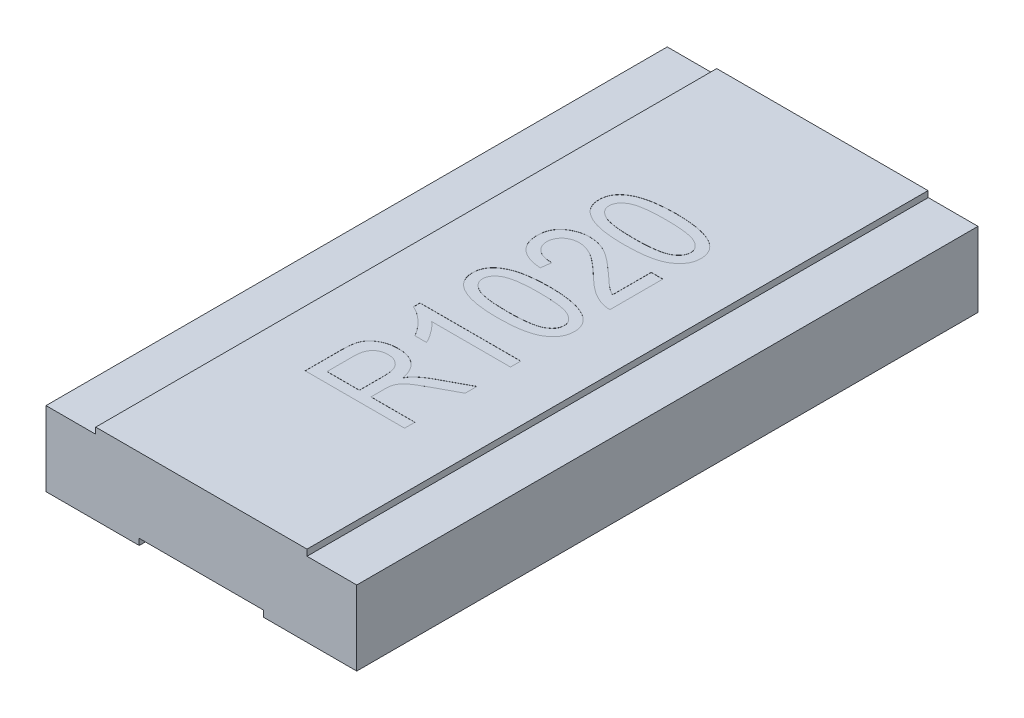
from build123d import *

# Parameters (mm, degrees)
SKETCH1_W           = 2.4
SKETCH1_H           = 0.5
BOSS_EXTRUDE1_DEPTH = 2.5
BOSS_EXTRUDE4_DEPTH = 2.499
SKETCH6_W           = 1.7
SKETCH6_H           = 0.1
BOSS_EXTRUDE6_DEPTH = 2.498
CUT_EXTRUDE1_DEPTH  = 0.001


with BuildPart() as part:
    # Sketch1 → Boss-Extrude1 (new body, symmetric)
    with BuildSketch(Plane.XY):
        with Locations((0, 0.25)):
            Rectangle(SKETCH1_W, SKETCH1_H)
    extrude(amount=BOSS_EXTRUDE1_DEPTH, both=True)

    # Sketch4 → Boss-Extrude4 (add, symmetric)
    with BuildSketch(Plane.XY.offset(0.001)):
        Polygon((-0.85, 0.5), (-1.2, 0.5), (-1.2, 0), (-0.5, 0), (-0.5, -0.05), (-1.25, -0.05), (-1.25, 0.55), (-0.85, 0.55), align=None)
        Polygon((0.5, 0), (0.5, -0.05), (1.25, -0.05), (1.25, 0.55), (0.85, 0.55), (0.85, 0.5), (1.2, 0.5), (1.2, 0), align=None)
    extrude(amount=BOSS_EXTRUDE4_DEPTH, both=True)

    # Sketch6 → Boss-Extrude6 (add, symmetric)
    with BuildSketch(Plane.XY.offset(0.002)):
        with Locations((0, 0.55)):
            Rectangle(SKETCH6_W, SKETCH6_H)
    extrude(amount=BOSS_EXTRUDE6_DEPTH, both=True)

    # Sketch7 → Cut-Extrude1 (cut)
    with BuildSketch(Plane(origin=(0, 0.6, 0), x_dir=(1, 0, 0), z_dir=(0, 1, 0))):
        with BuildLine():
            Line((0.4, -1.265101547), (-0.4, -1.265101547))
            Line((-0.4, -1.265101547), (-0.4, -0.971270379))
            add(Edge.make_bspline(
                [(-0.4, -0.971270379), (-0.39995785, -0.963855116), (-0.399876264, -0.949502111), (-0.398680595, -0.92871139), (-0.396945836, -0.909373199), (-0.394525945, -0.891550439), (-0.391555504, -0.875247766), (-0.387561775, -0.860533054), (-0.383180064, -0.847201773), (-0.375944491, -0.831509786), (-0.364511837, -0.813744854), (-0.347436487, -0.794426273), (-0.326220815, -0.777569521), (-0.30187047, -0.762556091), (-0.274523417, -0.750230301), (-0.244701857, -0.741498445), (-0.212795149, -0.736227432), (-0.190821454, -0.735569197), (-0.179545455, -0.735231418)],
                knots=[0, 0, 0, 0, 2.2243e-05, 4.3053e-05, 6.2453e-05, 8.0476e-05, 9.7e-05, 0.000112121, 0.000126187, 0.000139045, 0.000163859, 0.000189272, 0.000216045, 0.000244834, 0.000274916, 0.000305734, 0.000337814, 0.000371627, 0.000371627, 0.000371627, 0.000371627], degree=3))
            add(Edge.make_bspline(
                [(-0.179545455, -0.735231418), (-0.172073315, -0.73540863), (-0.157477891, -0.735754781), (-0.136082698, -0.737836039), (-0.115748432, -0.741507088), (-0.096577728, -0.746961367), (-0.078391935, -0.753512258), (-0.061438311, -0.761920334), (-0.045471195, -0.771634303), (-0.030623881, -0.782898063), (-0.016999042, -0.795586057), (-0.004519285, -0.809571398), (0.006298816, -0.825172308), (0.016103374, -0.84190487), (0.02456307, -0.860059036), (0.031704326, -0.879545814), (0.037352601, -0.900433785), (0.040135474, -0.91486519), (0.041558442, -0.922244405)],
                knots=[0, 0, 0, 0, 2.2417e-05, 4.3788e-05, 6.4421e-05, 8.4312e-05, 0.000103521, 0.000122325, 0.000140979, 0.000159518, 0.000178127, 0.000196758, 0.00021563, 0.000234981, 0.00025488, 0.000275628, 0.00029717, 0.000319711, 0.000319711, 0.000319711, 0.000319711], degree=3))
            add(Edge.make_bspline(
                [(0.041558442, -0.922244405), (0.044555926, -0.916779777), (0.050276332, -0.90635107), (0.059782903, -0.892318905), (0.068890204, -0.880021833), (0.075678481, -0.873203531), (0.078896104, -0.869971677)],
                knots=[0, 0, 0, 0, 1.8686e-05, 3.566e-05, 5.0824e-05, 6.4488e-05, 6.4488e-05, 6.4488e-05, 6.4488e-05], degree=3))
            add(Edge.make_bspline(
                [(0.078896104, -0.869971677), (0.086721081, -0.863488896), (0.102459028, -0.850450434), (0.127566949, -0.832576778), (0.153686209, -0.81545617), (0.172059762, -0.805402143), (0.181331169, -0.80032882)],
                knots=[0, 0, 0, 0, 3.0475e-05, 6.1292e-05, 9.2407e-05, 0.000124101, 0.000124101, 0.000124101, 0.000124101], degree=3))
            Line((0.181331169, -0.80032882), (0.4, -0.683283366))
            Line((0.4, -0.683283366), (0.4, -0.777763885))
            Line((0.4, -0.777763885), (0.228896104, -0.870134015))
            add(Edge.make_bspline(
                [(0.228896104, -0.870134015), (0.220873279, -0.874437048), (0.205527529, -0.882667722), (0.183738651, -0.894882687), (0.164088927, -0.906238078), (0.146556532, -0.916711609), (0.131335827, -0.926468311), (0.118191897, -0.935209203), (0.107318298, -0.943305263), (0.095943991, -0.952720948), (0.084495486, -0.964071732), (0.072798294, -0.977253692), (0.063759525, -0.990514275), (0.056864975, -1.004000115), (0.052325538, -1.018849089), (0.048926934, -1.035579824), (0.047078549, -1.054942071), (0.04686627, -1.068669394), (0.046753247, -1.075978171)],
                knots=[0, 0, 0, 0, 2.7311e-05, 5.224e-05, 7.4933e-05, 9.5396e-05, 0.000113499, 0.000129168, 0.00014274, 0.000154151, 0.000173437, 0.000191045, 0.000206939, 0.000221459, 0.000236296, 0.000253361, 0.000272615, 0.000294541, 0.000294541, 0.000294541, 0.000294541], degree=3))
            Line((0.046753247, -1.075978171), (0.046753247, -1.181984664))
            Line((0.046753247, -1.181984664), (0.4, -1.181984664))
            Line((0.4, -1.181984664), (0.4, -1.265101547))
        make_face()
        with BuildLine():
            Line((-0.046753247, -1.181984664), (-0.046753247, -0.987017132))
            add(Edge.make_bspline(
                [(-0.046753247, -0.987017132), (-0.046948354, -0.977001093), (-0.047314005, -0.95823006), (-0.049742591, -0.931969507), (-0.054137093, -0.909554996), (-0.060538394, -0.890569429), (-0.069017501, -0.874376486), (-0.079527286, -0.860291509), (-0.092074494, -0.847857466), (-0.106691715, -0.837504803), (-0.122754899, -0.828656947), (-0.140496417, -0.822848764), (-0.159345231, -0.818852845), (-0.172380378, -0.81851922), (-0.179058442, -0.818348301)],
                knots=[0, 0, 0, 0, 3.0048e-05, 5.6313e-05, 7.9013e-05, 9.8419e-05, 0.00011621, 0.000133613, 0.000150946, 0.000168969, 0.000187198, 0.000205731, 0.00022477, 0.00024477, 0.00024477, 0.00024477, 0.00024477], degree=3))
            add(Edge.make_bspline(
                [(-0.179058442, -0.818348301), (-0.183878219, -0.818496201), (-0.193274501, -0.818784536), (-0.207043887, -0.82035962), (-0.219990172, -0.82326522), (-0.232159497, -0.827388158), (-0.243526929, -0.832520018), (-0.254097057, -0.838962505), (-0.263769813, -0.846618565), (-0.272785251, -0.855231718), (-0.280850043, -0.865032989), (-0.28757401, -0.876161152), (-0.293475167, -0.888266536), (-0.298386538, -0.901513593), (-0.302052756, -0.915942094), (-0.304585918, -0.931480719), (-0.306284106, -0.948072585), (-0.30642228, -0.959523445), (-0.306493506, -0.965426223)],
                knots=[0, 0, 0, 0, 1.4463e-05, 2.8195e-05, 4.1507e-05, 5.4187e-05, 6.6682e-05, 7.8848e-05, 9.1221e-05, 0.000103621, 0.000116196, 0.000129171, 0.00014253, 0.000156553, 0.000171475, 0.000187115, 0.000203752, 0.000221454, 0.000221454, 0.000221454, 0.000221454], degree=3))
            Line((-0.306493506, -0.965426223), (-0.306493506, -1.181984664))
            Line((-0.306493506, -1.181984664), (-0.046753247, -1.181984664))
        make_face(mode=Mode.SUBTRACT)
        with BuildLine():
            Line((0.4, -0.330036612), (0.4, -0.413153496))
            Line((0.4, -0.413153496), (-0.233766234, -0.413153496))
            add(Edge.make_bspline(
                [(-0.233766234, -0.413153496), (-0.22789281, -0.418259983), (-0.215720145, -0.428843174), (-0.198387445, -0.447148824), (-0.180717222, -0.467729046), (-0.163347096, -0.490308414), (-0.146803147, -0.513467991), (-0.13198719, -0.536164213), (-0.119317397, -0.557883571), (-0.112407645, -0.572413015), (-0.109090909, -0.579387262)],
                knots=[0, 0, 0, 0, 2.3337e-05, 4.8365e-05, 7.5534e-05, 0.000104694, 0.000133793, 0.0001609, 0.000185989, 0.000209148, 0.000209148, 0.000209148, 0.000209148], degree=3))
            Line((-0.109090909, -0.579387262), (-0.202597403, -0.579387262))
            add(Edge.make_bspline(
                [(-0.202597403, -0.579387262), (-0.209347315, -0.56817847), (-0.222789341, -0.545856864), (-0.246047405, -0.514513351), (-0.27134637, -0.485063397), (-0.298564664, -0.45813021), (-0.326499348, -0.433908583), (-0.354510545, -0.413262457), (-0.382167744, -0.396279995), (-0.40119783, -0.387954189), (-0.41038961, -0.383932716)],
                knots=[0, 0, 0, 0, 3.9234e-05, 7.8131e-05, 0.000116922, 0.000155606, 0.0001929, 0.00022774, 0.000259924, 0.000289992, 0.000289992, 0.000289992, 0.000289992], degree=3))
            Line((-0.41038961, -0.383932716), (-0.41038961, -0.330036612))
            Line((-0.41038961, -0.330036612), (0.4, -0.330036612))
        make_face()
        with BuildLine():
            add(Edge.make_bspline(
                [(0.000324675, -0.122244405), (-0.016021042, -0.122112435), (-0.047760494, -0.121856181), (-0.09379487, -0.119207284), (-0.136801588, -0.11503034), (-0.17672127, -0.109346522), (-0.213565673, -0.101666694), (-0.247423741, -0.092569134), (-0.278200626, -0.081526289), (-0.30592122, -0.068951131), (-0.330477704, -0.054681469), (-0.351792814, -0.038669027), (-0.370041697, -0.02114344), (-0.384847394, -0.001745618), (-0.396328317, 0.019227557), (-0.404536915, 0.041819927), (-0.409503157, 0.066013289), (-0.410090123, 0.082710307), (-0.41038961, 0.091229621)],
                knots=[0, 0, 0, 0, 4.9033e-05, 9.521e-05, 0.000138274, 0.000178635, 0.000216108, 0.000251119, 0.000283726, 0.00031409, 0.000342322, 0.00036875, 0.000393892, 0.000417983, 0.000441667, 0.000465342, 0.000489857, 0.000515395, 0.000515395, 0.000515395, 0.000515395], degree=3))
            add(Edge.make_bspline(
                [(-0.41038961, 0.091229621), (-0.410169658, 0.098826563), (-0.409737438, 0.113755033), (-0.405457538, 0.135431419), (-0.399077317, 0.155985643), (-0.389661722, 0.17511877), (-0.377673073, 0.193047285), (-0.36292492, 0.209558156), (-0.345731248, 0.2250786), (-0.332693004, 0.233915813), (-0.325974026, 0.238469881)],
                knots=[0, 0, 0, 0, 2.2764e-05, 4.4733e-05, 6.6039e-05, 8.7167e-05, 0.000108463, 0.000130546, 0.000153424, 0.000177749, 0.000177749, 0.000177749, 0.000177749], degree=3))
            add(Edge.make_bspline(
                [(-0.325974026, 0.238469881), (-0.316932513, 0.243757062), (-0.298129732, 0.254752314), (-0.266625089, 0.26787697), (-0.231391283, 0.278974552), (-0.192392981, 0.288232291), (-0.149548038, 0.294953917), (-0.103030259, 0.300194582), (-0.052638354, 0.303249271), (-0.017753077, 0.303565665), (0.000324675, 0.303729621)],
                knots=[0, 0, 0, 0, 3.1393e-05, 6.5286e-05, 0.000102096, 0.000142141, 0.000185403, 0.000232121, 0.00028254, 0.00033677, 0.00033677, 0.00033677, 0.00033677], degree=3))
            add(Edge.make_bspline(
                [(0.000324675, 0.303729621), (0.016562275, 0.303598346), (0.048085644, 0.30334349), (0.093848365, 0.300683555), (0.136641334, 0.296522752), (0.176444849, 0.290804382), (0.21320116, 0.283198918), (0.246943754, 0.273969999), (0.27775117, 0.263224052), (0.305463525, 0.250547751), (0.330139101, 0.236325562), (0.35156697, 0.220422432), (0.369744183, 0.202836017), (0.384714293, 0.183615626), (0.396154173, 0.162500504), (0.4045563, 0.139909505), (0.409505394, 0.115577436), (0.410090267, 0.098828081), (0.41038961, 0.090255595)],
                knots=[0, 0, 0, 0, 4.8708e-05, 9.4561e-05, 0.000137464, 0.000177664, 0.000215137, 0.000249992, 0.000282544, 0.000312908, 0.00034128, 0.000367838, 0.00039275, 0.000416941, 0.000440624, 0.000464508, 0.000489022, 0.000514723, 0.000514723, 0.000514723, 0.000514723], degree=3))
            add(Edge.make_bspline(
                [(0.41038961, 0.090255595), (0.410102249, 0.082607501), (0.409537263, 0.067570486), (0.40525013, 0.045503476), (0.397835391, 0.02463294), (0.387715352, 0.004750146), (0.37448733, -0.013836791), (0.358603182, -0.031566733), (0.339632377, -0.048016827), (0.317846299, -0.063685929), (0.292434451, -0.077758524), (0.262894461, -0.089636104), (0.229327034, -0.099840396), (0.191493763, -0.107875867), (0.149631232, -0.114611097), (0.103536364, -0.118909919), (0.05333605, -0.12171659), (0.018456685, -0.122063871), (0.000324675, -0.122244405)],
                knots=[0, 0, 0, 0, 2.2936e-05, 4.5095e-05, 6.7121e-05, 8.9192e-05, 0.000111801, 0.000135367, 0.000160443, 0.000186976, 0.000215752, 0.000247346, 0.000282316, 0.000320878, 0.000363286, 0.000409452, 0.00045969, 0.000514082, 0.000514082, 0.000514082, 0.000514082], degree=3))
        make_face()
        with BuildLine():
            add(Edge.make_bspline(
                [(0, -0.039127522), (0.015585433, -0.038980974), (0.045412307, -0.038700515), (0.088138333, -0.037197996), (0.126801799, -0.034296169), (0.161480386, -0.030322961), (0.192171875, -0.025216691), (0.218937291, -0.019062695), (0.241618648, -0.011511026), (0.260612284, -0.00280719), (0.276390845, 0.006992362), (0.289995294, 0.017192196), (0.301500674, 0.028101141), (0.310858817, 0.039751232), (0.318307973, 0.05198922), (0.323544637, 0.064977356), (0.32676959, 0.078625897), (0.327103684, 0.087965203), (0.327272727, 0.09269066)],
                knots=[0, 0, 0, 0, 4.6758e-05, 8.9483e-05, 0.00012823, 0.000163045, 0.000194164, 0.00022153, 0.00024535, 0.000265758, 0.000284051, 0.000300967, 0.000316697, 0.000331477, 0.000345676, 0.000359513, 0.000373336, 0.000387492, 0.000387492, 0.000387492, 0.000387492], degree=3))
            add(Edge.make_bspline(
                [(0.327272727, 0.09269066), (0.327118523, 0.097150594), (0.326811477, 0.106031032), (0.323300853, 0.118978506), (0.318137694, 0.131449963), (0.310698881, 0.143317716), (0.300920242, 0.154317546), (0.289296481, 0.164953664), (0.27557117, 0.17499212), (0.259580996, 0.184577709), (0.240515874, 0.193369637), (0.217644644, 0.200624092), (0.190931752, 0.206860901), (0.160354738, 0.212017235), (0.125814937, 0.215717867), (0.087382896, 0.218698347), (0.044978911, 0.220179225), (0.015422904, 0.22046409), (0, 0.220612738)],
                knots=[0, 0, 0, 0, 1.3347e-05, 2.6577e-05, 3.9963e-05, 5.3747e-05, 6.8362e-05, 8.3988e-05, 0.000100937, 0.000119284, 0.00013984, 0.000163763, 0.000191128, 0.000222087, 0.000256722, 0.000295307, 0.000337708, 0.000383979, 0.000383979, 0.000383979, 0.000383979], degree=3))
            add(Edge.make_bspline(
                [(0, 0.220612738), (-0.015585365, 0.220464955), (-0.04546618, 0.22018162), (-0.088247116, 0.218691318), (-0.127016652, 0.215768381), (-0.161752921, 0.211822751), (-0.192495499, 0.20669937), (-0.219264814, 0.200552343), (-0.241934804, 0.192983582), (-0.260920639, 0.184349607), (-0.276556352, 0.174422289), (-0.290225728, 0.164365976), (-0.30144006, 0.153159855), (-0.310923572, 0.141563039), (-0.31829914, 0.129157868), (-0.323577556, 0.1159721), (-0.326752016, 0.102094957), (-0.327098428, 0.092598656), (-0.327272727, 0.08782053)],
                knots=[0, 0, 0, 0, 4.6758e-05, 8.9646e-05, 0.000128392, 0.000163369, 0.000194487, 0.000221853, 0.000245673, 0.000266082, 0.000284236, 0.000301152, 0.000316879, 0.000331659, 0.000345998, 0.000359985, 0.000374124, 0.000388443, 0.000388443, 0.000388443, 0.000388443], degree=3))
            add(Edge.make_bspline(
                [(-0.327272727, 0.08782053), (-0.327122931, 0.083359578), (-0.326826428, 0.07452969), (-0.323295988, 0.061694161), (-0.318147158, 0.049370028), (-0.310636877, 0.03771437), (-0.301094319, 0.026629206), (-0.289497135, 0.016037577), (-0.275672715, 0.006205747), (-0.259757937, -0.003509582), (-0.240540042, -0.011904231), (-0.217800732, -0.019407358), (-0.191008933, -0.025315012), (-0.160412785, -0.030540162), (-0.125813369, -0.034228301), (-0.08738338, -0.037214473), (-0.044978772, -0.038693622), (-0.015422856, -0.038978741), (0, -0.039127522)],
                knots=[0, 0, 0, 0, 1.3347e-05, 2.6419e-05, 3.9656e-05, 5.3303e-05, 6.7812e-05, 8.3438e-05, 0.000100291, 0.000118638, 0.000139275, 0.000163043, 0.000190372, 0.00022149, 0.000256126, 0.00029471, 0.000337112, 0.000383382, 0.000383382, 0.000383382, 0.000383382], degree=3))
        make_face(mode=Mode.SUBTRACT)
        with BuildLine():
            Line((0.306493506, 0.81282053), (0.4, 0.81282053))
            Line((0.4, 0.81282053), (0.4, 0.386846504))
            add(Edge.make_bspline(
                [(0.4, 0.386846504), (0.39512792, 0.386826782), (0.385257008, 0.386786823), (0.37020793, 0.388115329), (0.354794505, 0.390844858), (0.338811118, 0.394330191), (0.322467973, 0.399272002), (0.305685704, 0.405321741), (0.288505921, 0.412459716), (0.270827561, 0.420818377), (0.252478278, 0.430582857), (0.233546317, 0.442378477), (0.213679968, 0.45585768), (0.193126969, 0.471347035), (0.171691966, 0.488567877), (0.149474239, 0.507605191), (0.126351708, 0.52837947), (0.110993752, 0.543183486), (0.103084416, 0.550807543)],
                knots=[0, 0, 0, 0, 1.4611e-05, 2.9603e-05, 4.5242e-05, 6.1547e-05, 7.8651e-05, 9.6418e-05, 0.000115049, 0.000134438, 0.000155065, 0.000177367, 0.000201321, 0.000227067, 0.00025455, 0.000283797, 0.000314832, 0.000347786, 0.000347786, 0.000347786, 0.000347786], degree=3))
            add(Edge.make_bspline(
                [(0.103084416, 0.550807543), (0.09392156, 0.559666289), (0.076279193, 0.576723114), (0.050229157, 0.600728966), (0.026015973, 0.622540694), (0.003201794, 0.641722513), (-0.017902657, 0.658614971), (-0.037267205, 0.673388025), (-0.055331317, 0.685335669), (-0.076586339, 0.698235728), (-0.101890107, 0.710534101), (-0.131385651, 0.72140656), (-0.159899065, 0.72843156), (-0.178697352, 0.729287873), (-0.187824675, 0.729703647)],
                knots=[0, 0, 0, 0, 3.8234e-05, 7.3616e-05, 0.000106268, 0.000135991, 0.000163017, 0.000187368, 0.000209025, 0.000227956, 0.000261934, 0.00029321, 0.000322193, 0.000349548, 0.000349548, 0.000349548, 0.000349548], degree=3))
            add(Edge.make_bspline(
                [(-0.187824675, 0.729703647), (-0.192863695, 0.729645689), (-0.202705426, 0.729532489), (-0.217078053, 0.7276081), (-0.230749291, 0.724864744), (-0.243814956, 0.721238926), (-0.256071162, 0.716111803), (-0.267603487, 0.709898763), (-0.278563817, 0.702794318), (-0.288571569, 0.694504092), (-0.297599959, 0.685442291), (-0.305682462, 0.675869364), (-0.312288783, 0.66562395), (-0.31776098, 0.654917179), (-0.321947988, 0.64368491), (-0.325085218, 0.631955519), (-0.326867489, 0.619693092), (-0.327136309, 0.611364994), (-0.327272727, 0.607138712)],
                knots=[0, 0, 0, 0, 1.5105e-05, 2.9502e-05, 4.3415e-05, 5.6928e-05, 7.0102e-05, 8.3175e-05, 9.6188e-05, 0.00010922, 0.000122077, 0.000134527, 0.00014673, 0.000158563, 0.000170534, 0.000182622, 0.000194928, 0.000207607, 0.000207607, 0.000207607, 0.000207607], degree=3))
            add(Edge.make_bspline(
                [(-0.327272727, 0.607138712), (-0.327177514, 0.602581898), (-0.326991654, 0.593686786), (-0.324667417, 0.580725332), (-0.321584679, 0.568291423), (-0.316711045, 0.556540481), (-0.310820669, 0.545248675), (-0.303131832, 0.534880517), (-0.294550988, 0.524839719), (-0.284484341, 0.515610027), (-0.273053691, 0.507371342), (-0.260569005, 0.499976079), (-0.246719487, 0.494015435), (-0.231847415, 0.489006155), (-0.21577474, 0.485071368), (-0.198551091, 0.482444295), (-0.180183837, 0.480516798), (-0.167537953, 0.480408602), (-0.161038961, 0.480352998)],
                knots=[0, 0, 0, 0, 1.3652e-05, 2.6649e-05, 3.9407e-05, 5.2007e-05, 6.4718e-05, 7.7512e-05, 9.0631e-05, 0.000104303, 0.000118363, 0.000132841, 0.000147741, 0.000163501, 0.000179881, 0.000197308, 0.000215739, 0.000235226, 0.000235226, 0.000235226, 0.000235226], degree=3))
            Line((-0.161038961, 0.480352998), (-0.171428571, 0.397236115))
            add(Edge.make_bspline(
                [(-0.171428571, 0.397236115), (-0.181073636, 0.398092657), (-0.1997855, 0.399754387), (-0.226873639, 0.404114642), (-0.252007272, 0.410164082), (-0.275434001, 0.417349109), (-0.29687389, 0.426374779), (-0.316719481, 0.436533359), (-0.334625583, 0.448412834), (-0.350622211, 0.461765171), (-0.364649104, 0.476478484), (-0.376840285, 0.492285242), (-0.38741355, 0.509111067), (-0.39580649, 0.527192775), (-0.40235066, 0.546410757), (-0.407029461, 0.566693385), (-0.409819822, 0.588121867), (-0.410196876, 0.602747221), (-0.41038961, 0.610223128)],
                knots=[0, 0, 0, 0, 2.9043e-05, 5.6346e-05, 8.2215e-05, 0.000106552, 0.000129766, 0.000151912, 0.000173343, 0.000194087, 0.000214295, 0.0002342, 0.000253886, 0.000273785, 0.000293857, 0.000314689, 0.000336133, 0.000358557, 0.000358557, 0.000358557, 0.000358557], degree=3))
            add(Edge.make_bspline(
                [(-0.41038961, 0.610223128), (-0.410154423, 0.618295443), (-0.409696474, 0.634013581), (-0.406632452, 0.656883457), (-0.401351124, 0.678277408), (-0.393585985, 0.698040367), (-0.384049536, 0.716387192), (-0.372205632, 0.733151946), (-0.358125112, 0.74831717), (-0.342074418, 0.761800876), (-0.324753415, 0.773720346), (-0.3066396, 0.784119995), (-0.288035554, 0.793141084), (-0.268733616, 0.800191264), (-0.248993006, 0.80607893), (-0.228514436, 0.809777687), (-0.207534202, 0.812381587), (-0.193352427, 0.81267339), (-0.186201299, 0.81282053)],
                knots=[0, 0, 0, 0, 2.4215e-05, 4.7151e-05, 6.9081e-05, 9.0154e-05, 0.000110704, 0.000130972, 0.000151535, 0.000172613, 0.000193732, 0.000214532, 0.000235226, 0.00025567, 0.000276119, 0.000296941, 0.000318024, 0.000339467, 0.000339467, 0.000339467, 0.000339467], degree=3))
            add(Edge.make_bspline(
                [(-0.186201299, 0.81282053), (-0.179758445, 0.812681896), (-0.166956679, 0.812406433), (-0.147855717, 0.810614522), (-0.129011553, 0.807451465), (-0.110242993, 0.80334438), (-0.091840651, 0.797516384), (-0.07351221, 0.790918827), (-0.055464603, 0.782916329), (-0.037344912, 0.773469851), (-0.018514493, 0.762406517), (0.001381249, 0.749160805), (0.022861937, 0.733893065), (0.045675242, 0.71629258), (0.070073484, 0.696640554), (0.095863026, 0.674683478), (0.123096534, 0.650495279), (0.141585576, 0.633467256), (0.151136364, 0.62467118)],
                knots=[0, 0, 0, 0, 1.9329e-05, 3.8406e-05, 5.7488e-05, 7.6628e-05, 9.5988e-05, 0.000115349, 0.000135046, 0.000155159, 0.000176625, 0.000200533, 0.00022684, 0.000255672, 0.000286958, 0.000320819, 0.000357272, 0.000396224, 0.000396224, 0.000396224, 0.000396224], degree=3))
            add(Edge.make_bspline(
                [(0.151136364, 0.62467118), (0.157073896, 0.619081557), (0.168420996, 0.608399339), (0.184880276, 0.593374673), (0.19964141, 0.579606966), (0.213078071, 0.567564195), (0.224902458, 0.556855314), (0.235501549, 0.548052761), (0.244358981, 0.540484067), (0.258552351, 0.529442436), (0.278572735, 0.515507509), (0.297401215, 0.505813476), (0.306493506, 0.501132219)],
                knots=[0, 0, 0, 0, 2.4463e-05, 4.6752e-05, 6.6856e-05, 8.5016e-05, 0.000100884, 0.000114706, 0.000126346, 0.000135829, 0.000168653, 0.000199307, 0.000199307, 0.000199307, 0.000199307], degree=3))
            Line((0.306493506, 0.501132219), (0.306493506, 0.81282053))
        make_face()
        with BuildLine():
            add(Edge.make_bspline(
                [(0.000324675, 0.895937414), (-0.016021042, 0.896069384), (-0.047760494, 0.896325637), (-0.09379487, 0.898974535), (-0.136801588, 0.903151478), (-0.17672127, 0.908835297), (-0.213565673, 0.916515125), (-0.247423741, 0.925612684), (-0.278200626, 0.936655529), (-0.30592122, 0.949230687), (-0.330477704, 0.963500349), (-0.351792814, 0.979512791), (-0.370041697, 0.997038378), (-0.384847394, 1.016436201), (-0.396328317, 1.037409375), (-0.404536915, 1.060001745), (-0.409503157, 1.084195108), (-0.410090123, 1.100892125), (-0.41038961, 1.10941144)],
                knots=[0, 0, 0, 0, 4.9033e-05, 9.521e-05, 0.000138274, 0.000178635, 0.000216108, 0.000251119, 0.000283726, 0.00031409, 0.000342322, 0.00036875, 0.000393892, 0.000417983, 0.000441667, 0.000465342, 0.000489857, 0.000515395, 0.000515395, 0.000515395, 0.000515395], degree=3))
            add(Edge.make_bspline(
                [(-0.41038961, 1.10941144), (-0.410169658, 1.117008382), (-0.409737438, 1.131936852), (-0.405457538, 1.153613237), (-0.399077317, 1.174167461), (-0.389661722, 1.193300588), (-0.377673073, 1.211229103), (-0.36292492, 1.227739974), (-0.345731248, 1.243260418), (-0.332693004, 1.252097632), (-0.325974026, 1.256651699)],
                knots=[0, 0, 0, 0, 2.2764e-05, 4.4733e-05, 6.6039e-05, 8.7167e-05, 0.000108463, 0.000130546, 0.000153424, 0.000177749, 0.000177749, 0.000177749, 0.000177749], degree=3))
            add(Edge.make_bspline(
                [(-0.325974026, 1.256651699), (-0.316932513, 1.261938881), (-0.298129732, 1.272934132), (-0.266625089, 1.286058788), (-0.231391283, 1.29715637), (-0.192392981, 1.306414109), (-0.149548038, 1.313135735), (-0.103030259, 1.3183764), (-0.052638354, 1.32143109), (-0.017753077, 1.321747483), (0.000324675, 1.32191144)],
                knots=[0, 0, 0, 0, 3.1393e-05, 6.5286e-05, 0.000102096, 0.000142141, 0.000185403, 0.000232121, 0.00028254, 0.00033677, 0.00033677, 0.00033677, 0.00033677], degree=3))
            add(Edge.make_bspline(
                [(0.000324675, 1.32191144), (0.016562275, 1.321780164), (0.048085644, 1.321525308), (0.093848365, 1.318865374), (0.136641334, 1.31470457), (0.176444849, 1.3089862), (0.21320116, 1.301380736), (0.246943754, 1.292151817), (0.27775117, 1.28140587), (0.305463525, 1.268729569), (0.330139101, 1.25450738), (0.35156697, 1.23860425), (0.369744183, 1.221017836), (0.384714293, 1.201797444), (0.396154173, 1.180682322), (0.4045563, 1.158091324), (0.409505394, 1.133759254), (0.410090267, 1.117009899), (0.41038961, 1.108437414)],
                knots=[0, 0, 0, 0, 4.8708e-05, 9.4561e-05, 0.000137464, 0.000177664, 0.000215137, 0.000249992, 0.000282544, 0.000312908, 0.00034128, 0.000367838, 0.00039275, 0.000416941, 0.000440624, 0.000464508, 0.000489022, 0.000514723, 0.000514723, 0.000514723, 0.000514723], degree=3))
            add(Edge.make_bspline(
                [(0.41038961, 1.108437414), (0.410102249, 1.100789319), (0.409537263, 1.085752304), (0.40525013, 1.063685294), (0.397835391, 1.042814758), (0.387715352, 1.022931964), (0.37448733, 1.004345027), (0.358603182, 0.986615085), (0.339632377, 0.970164991), (0.317846299, 0.95449589), (0.292434451, 0.940423295), (0.262894461, 0.928545714), (0.229327034, 0.918341422), (0.191493763, 0.910305951), (0.149631232, 0.903570721), (0.103536364, 0.899271899), (0.05333605, 0.896465228), (0.018456685, 0.896117947), (0.000324675, 0.895937414)],
                knots=[0, 0, 0, 0, 2.2936e-05, 4.5095e-05, 6.7121e-05, 8.9192e-05, 0.000111801, 0.000135367, 0.000160443, 0.000186976, 0.000215752, 0.000247346, 0.000282316, 0.000320878, 0.000363286, 0.000409452, 0.00045969, 0.000514082, 0.000514082, 0.000514082, 0.000514082], degree=3))
        make_face()
        with BuildLine():
            add(Edge.make_bspline(
                [(0, 0.979054297), (0.015585433, 0.979200845), (0.045412307, 0.979481303), (0.088138333, 0.980983822), (0.126801799, 0.983885649), (0.161480386, 0.987858857), (0.192171875, 0.992965127), (0.218937291, 0.999119123), (0.241618648, 1.006670792), (0.260612284, 1.015374629), (0.276390845, 1.02517418), (0.289995294, 1.035374014), (0.301500674, 1.046282959), (0.310858817, 1.05793305), (0.318307973, 1.070171038), (0.323544637, 1.083159174), (0.32676959, 1.096807715), (0.327103684, 1.106147021), (0.327272727, 1.110872478)],
                knots=[0, 0, 0, 0, 4.6758e-05, 8.9483e-05, 0.00012823, 0.000163045, 0.000194164, 0.00022153, 0.00024535, 0.000265758, 0.000284051, 0.000300967, 0.000316697, 0.000331477, 0.000345676, 0.000359513, 0.000373336, 0.000387492, 0.000387492, 0.000387492, 0.000387492], degree=3))
            add(Edge.make_bspline(
                [(0.327272727, 1.110872478), (0.327118523, 1.115332412), (0.326811477, 1.12421285), (0.323300853, 1.137160324), (0.318137694, 1.149631781), (0.310698881, 1.161499534), (0.300920242, 1.172499364), (0.289296481, 1.183135482), (0.27557117, 1.193173938), (0.259580996, 1.202759527), (0.240515874, 1.211551455), (0.217644644, 1.21880591), (0.190931752, 1.225042719), (0.160354738, 1.230199053), (0.125814937, 1.233899685), (0.087382896, 1.236880166), (0.044978911, 1.238361043), (0.015422904, 1.238645908), (0, 1.238794556)],
                knots=[0, 0, 0, 0, 1.3347e-05, 2.6577e-05, 3.9963e-05, 5.3747e-05, 6.8362e-05, 8.3988e-05, 0.000100937, 0.000119284, 0.00013984, 0.000163763, 0.000191128, 0.000222087, 0.000256722, 0.000295307, 0.000337708, 0.000383979, 0.000383979, 0.000383979, 0.000383979], degree=3))
            add(Edge.make_bspline(
                [(0, 1.238794556), (-0.015585365, 1.238646773), (-0.04546618, 1.238363439), (-0.088247116, 1.236873136), (-0.127016652, 1.2339502), (-0.161752921, 1.230004569), (-0.192495499, 1.224881189), (-0.219264814, 1.218734161), (-0.241934804, 1.2111654), (-0.260920639, 1.202531425), (-0.276556352, 1.192604107), (-0.290225728, 1.182547794), (-0.30144006, 1.171341673), (-0.310923572, 1.159744857), (-0.31829914, 1.147339686), (-0.323577556, 1.134153918), (-0.326752016, 1.120276775), (-0.327098428, 1.110780474), (-0.327272727, 1.106002349)],
                knots=[0, 0, 0, 0, 4.6758e-05, 8.9646e-05, 0.000128392, 0.000163369, 0.000194487, 0.000221853, 0.000245673, 0.000266082, 0.000284236, 0.000301152, 0.000316879, 0.000331659, 0.000345998, 0.000359985, 0.000374124, 0.000388443, 0.000388443, 0.000388443, 0.000388443], degree=3))
            add(Edge.make_bspline(
                [(-0.327272727, 1.106002349), (-0.327122931, 1.101541397), (-0.326826428, 1.092711509), (-0.323295988, 1.079875979), (-0.318147158, 1.067551846), (-0.310636877, 1.055896188), (-0.301094319, 1.044811024), (-0.289497135, 1.034219395), (-0.275672715, 1.024387565), (-0.259757937, 1.014672237), (-0.240540042, 1.006277587), (-0.217800732, 0.998774461), (-0.191008933, 0.992866806), (-0.160412785, 0.987641657), (-0.125813369, 0.983953517), (-0.08738338, 0.980967345), (-0.044978772, 0.979488196), (-0.015422856, 0.979203077), (0, 0.979054297)],
                knots=[0, 0, 0, 0, 1.3347e-05, 2.6419e-05, 3.9656e-05, 5.3303e-05, 6.7812e-05, 8.3438e-05, 0.000100291, 0.000118638, 0.000139275, 0.000163043, 0.000190372, 0.00022149, 0.000256126, 0.00029471, 0.000337112, 0.000383382, 0.000383382, 0.000383382, 0.000383382], degree=3))
        make_face(mode=Mode.SUBTRACT)
    extrude(amount=-CUT_EXTRUDE1_DEPTH, mode=Mode.SUBTRACT)


solid = part.part
